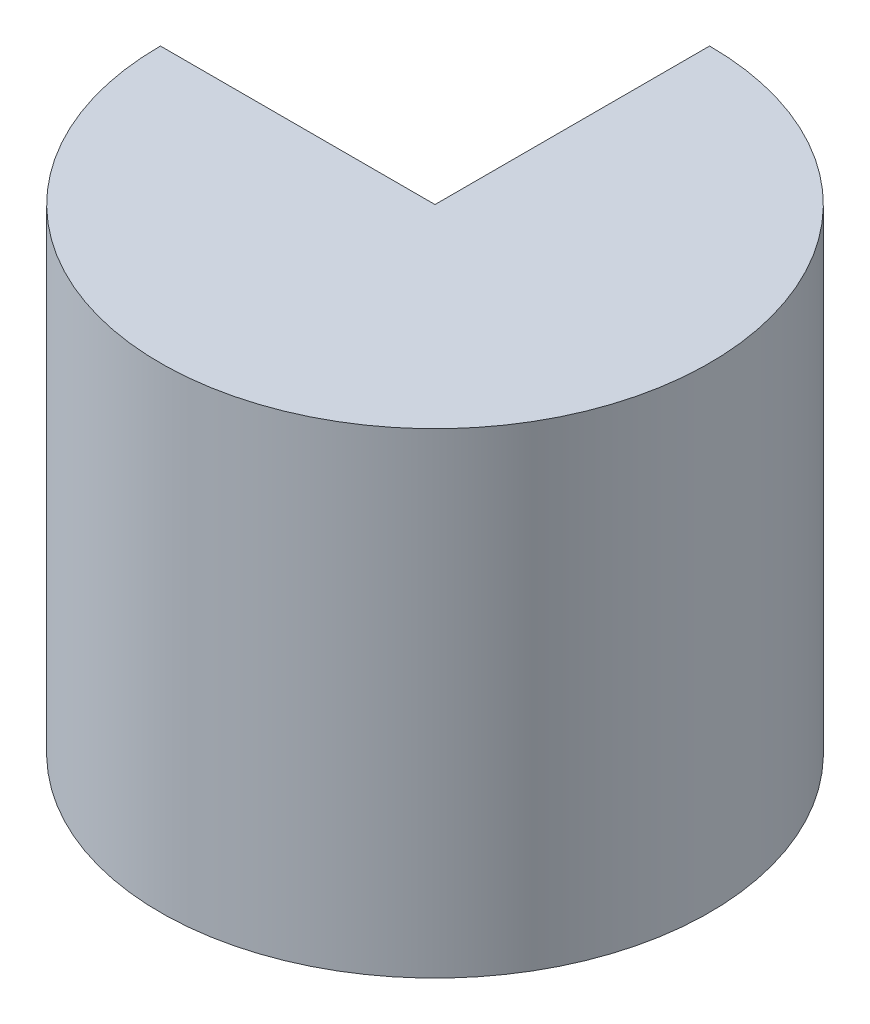
from build123d import *

# Parameters (mm, degrees)
REVOLVE2_ANGLE = 270


with BuildPart() as part:
    # Sketch1 → Revolve2 (revolve)
    with BuildSketch(Plane(origin=(0, 0, 0), x_dir=(0, 0, -1), z_dir=(1, 0, 0))):
        Polygon((25.654, 45.023434974), (25.654, 0.573434974), (3.175, 0.573434974), (0, 0.573434974), (0, 45.023434974), (3.175, 45.023434974), align=None)
    revolve(axis=Axis((0, 45.023434974, 0), (0, -1, 0)), revolution_arc=REVOLVE2_ANGLE)


solid = part.part
